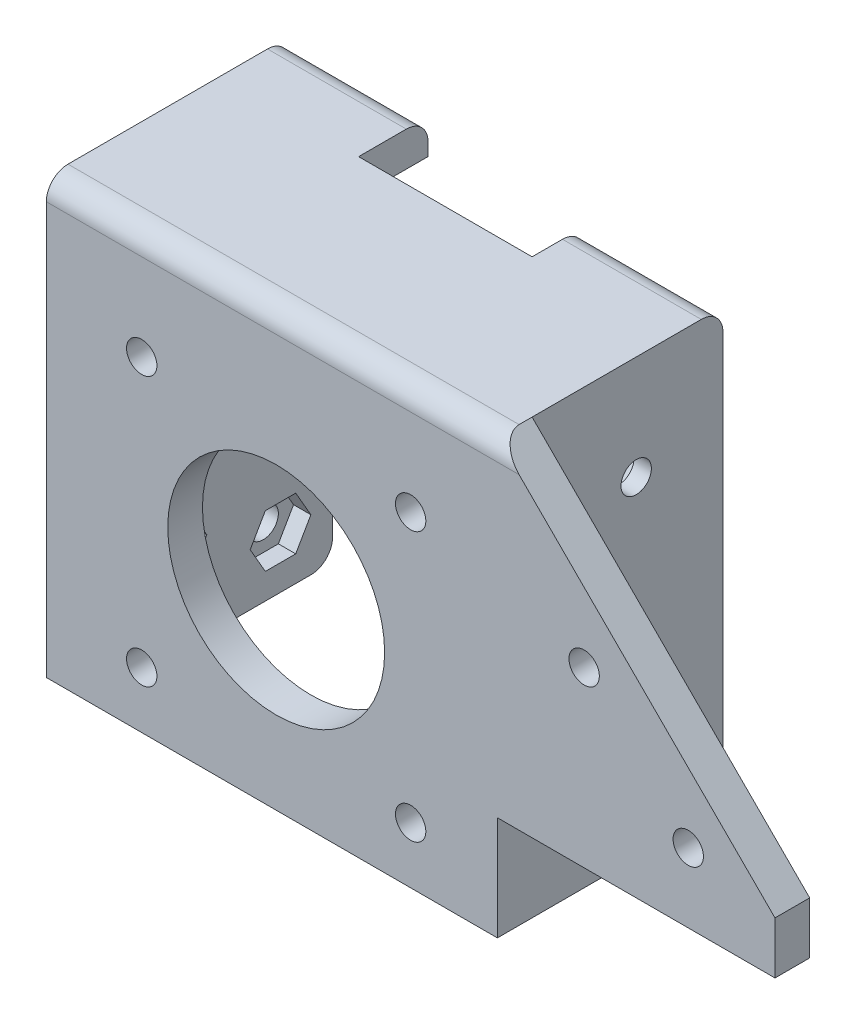
from build123d import *

# Parameters (mm, degrees)
BOSS_EXTRUDE1_DEPTH      = 4
SKETCH2_R                = 12.5
SKETCH2_R_2              = 1.75
CUT_EXTRUDE1_DEPTH       = 5
SKETCH9_R                = 1.75
CUT_EXTRUDE2_DEPTH       = 4
BOSS_EXTRUDE8_DEPTH      = 24
SKETCH18_R               = 1.75
CUT_EXTRUDE7_DEPTH       = 4
SKETCH19_R               = 1.75
CUT_EXTRUDE8_DEPTH       = 10
CUT_EXTRUDE9_DEPTH       = 50
FILLET1_R                = 2.5
CUT_EXTRUDE11_DEPTH      = 3
CUT_EXTRUDE11_DEPTH_BACK = 2
CUT_EXTRUDE12_DEPTH      = 2
CUT_EXTRUDE13_DEPTH      = 2
FILLET2_R                = 2.5


with BuildPart() as part:
    # Sketch1 → Boss-Extrude1 (new body)
    with BuildSketch(Plane.XY):
        Polygon((57.5, 18), (25.5, 50), (-26.5, 50), (-26.5, 0), (25.5, 0), (25.5, 12), (57.5, 12), align=None)
    extrude(amount=BOSS_EXTRUDE1_DEPTH)

    # Sketch2 → Cut-Extrude1 (cut, through all)
    with BuildSketch(Plane.XY.offset(4)):
        with Locations((0, 22)):
            Circle(SKETCH2_R)
        with Locations((15.5, 6.5)):
            Circle(SKETCH2_R_2)
        with Locations((15.5, 37.5)):
            Circle(SKETCH2_R_2)
        with Locations((-15.5, 37.5)):
            Circle(SKETCH2_R_2)
        with Locations((-15.5, 6.5)):
            Circle(SKETCH2_R_2)
    extrude(amount=-CUT_EXTRUDE1_DEPTH, mode=Mode.SUBTRACT)

    # Sketch9 → Cut-Extrude2 (cut)
    with BuildSketch(Plane(origin=(0, 0, 0), x_dir=(-1, 0, 0), z_dir=(0, 0, -1))):
        with Locations((-47.5, 20)):
            Circle(SKETCH9_R)
        with Locations((-35.5, 32)):
            Circle(SKETCH9_R)
    extrude(amount=-CUT_EXTRUDE2_DEPTH, mode=Mode.SUBTRACT)

    # Sketch17 → Boss-Extrude8 (add)
    with BuildSketch(Plane(origin=(0, 0, 0), x_dir=(-1, 0, 0), z_dir=(0, 0, -1))):
        Polygon((-25.5, 0), (-25.5, 50), (26.5, 50), (26.5, 0), (21.5, 0), (21.5, 46), (-21.5, 46), (-21.5, 0), align=None)
    extrude(amount=BOSS_EXTRUDE8_DEPTH)

    # Sketch18 → Cut-Extrude7 (cut)
    with BuildSketch(Plane(origin=(25.5, 0, 0), x_dir=(0, 0, -1), z_dir=(1, 0, 0))):
        with Locations((12, 38)):
            Circle(SKETCH18_R)
        with Locations((12, 20)):
            Circle(SKETCH18_R)
    extrude(amount=-CUT_EXTRUDE7_DEPTH, mode=Mode.SUBTRACT)

    # Sketch19 → Cut-Extrude8 (cut)
    with BuildSketch(Plane.ZY.offset(26.5)):
        with Locations((-18, 6)):
            Circle(SKETCH19_R)
        with Locations((-18, 41)):
            Circle(SKETCH19_R)
        with Locations((-6, 10)):
            Circle(SKETCH19_R)
        with Locations((-6, 45)):
            Circle(SKETCH19_R)
    extrude(amount=-CUT_EXTRUDE8_DEPTH, mode=Mode.SUBTRACT)

    # Sketch20 → Cut-Extrude9 (cut)
    with BuildSketch(Plane(origin=(0, 50, 0), x_dir=(1, 0, 0), z_dir=(0, 1, 0))):
        Polygon((25.5, 24), (-10.5, 24), (-10.5, 16), (9.5, 16), (9.5, 22), (25.5, 22), align=None)
    extrude(amount=-CUT_EXTRUDE9_DEPTH, mode=Mode.SUBTRACT)

    # Fillet1
    fillet1_edges = [part.edges().sort_by_distance(p)[0] for p in [
        (23.5, 0, -22),
        (17.5, 50, -22),
        (-24, 0, -24),
        (-18.5, 50, -24),
    ]]
    fillet(fillet1_edges, radius=FILLET1_R)

    # Sketch22 → Cut-Extrude11 (cut, two sides)
    with BuildSketch(Plane(origin=(-21.5, 0, 0), x_dir=(0, 0, -1), z_dir=(1, 0, 0))) as cut_extrude11_sk:
        Polygon((7.75, 41.968911087), (9.5, 45), (7.75, 48.031088913), (4.25, 48.031088913), (2.5, 45), (4.25, 41.968911087), align=None)
    extrude(amount=CUT_EXTRUDE11_DEPTH, mode=Mode.SUBTRACT)
    extrude(cut_extrude11_sk.sketch, amount=-CUT_EXTRUDE11_DEPTH_BACK, mode=Mode.SUBTRACT)

    # Sketch23 → Cut-Extrude12 (cut)
    with BuildSketch(Plane(origin=(-21.5, 0, 0), x_dir=(0, 0, -1), z_dir=(1, 0, 0))):
        Polygon((19.75, 37.968911087), (21.5, 41), (19.75, 44.031088913), (16.25, 44.031088913), (14.5, 41), (16.25, 37.968911087), align=None)
        Polygon((7.75, 6.968911087), (9.5, 10), (7.75, 13.031088913), (4.25, 13.031088913), (2.5, 10), (4.25, 6.968911087), align=None)
        Polygon((16.25, 2.968911087), (19.75, 2.968911087), (21.5, 6), (19.75, 9.031088913), (16.25, 9.031088913), (14.5, 6), align=None)
    extrude(amount=-CUT_EXTRUDE12_DEPTH, mode=Mode.SUBTRACT)

    # Sketch24 → Cut-Extrude13 (cut)
    with BuildSketch(Plane.ZY.offset(-21.5)):
        Polygon((-10.240287428, 41.047911581), (-13.759712572, 41.047911581), (-15.519425144, 38), (-13.759712572, 34.952088419), (-10.240287428, 34.952088419), (-8.480574856, 38), align=None)
        Polygon((-10.25, 23.031088913), (-13.75, 23.031088913), (-15.5, 20), (-13.75, 16.968911087), (-10.25, 16.968911087), (-8.5, 20), align=None)
    extrude(amount=-CUT_EXTRUDE13_DEPTH, mode=Mode.SUBTRACT)

    # Fillet2
    fillet2_edges = [part.edges().sort_by_distance(p)[0] for p in [
        (-0.5, 50, 4),
    ]]
    fillet(fillet2_edges, radius=FILLET2_R)


solid = part.part
